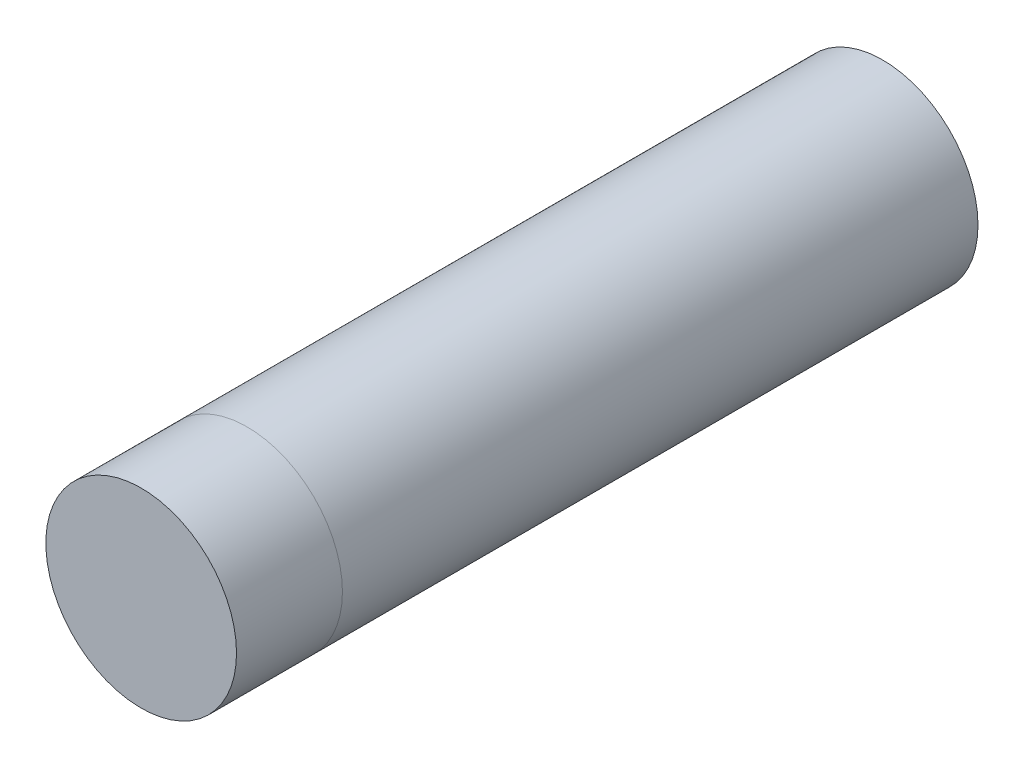
from build123d import *

# Parameters (mm, degrees)
SKETCH1_R           = 9
BOSS_EXTRUDE1_DEPTH = 60
SKETCH2_R           = 9
BOSS_EXTRUDE2_DEPTH = 10


with BuildPart() as part:
    # Sketch1 → Boss-Extrude1 (new body)
    with BuildSketch(Plane.XY):
        Circle(SKETCH1_R)
    extrude(amount=BOSS_EXTRUDE1_DEPTH)


with BuildPart() as body_2:
    # Sketch2 → Boss-Extrude2 (new body)
    with BuildSketch(Plane.XY.offset(60)):
        Circle(SKETCH2_R)
    extrude(amount=BOSS_EXTRUDE2_DEPTH)


solid = Compound([part.part, body_2.part])
